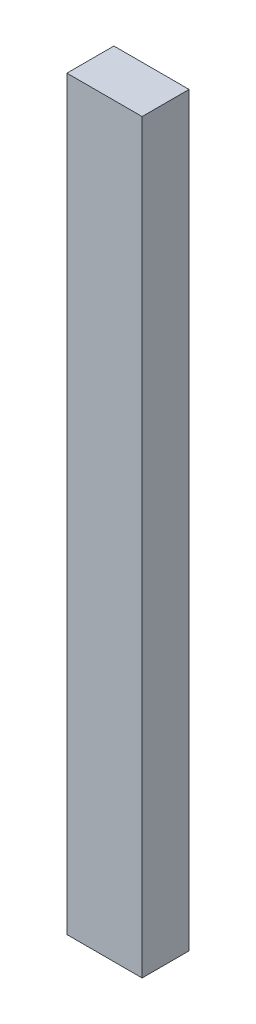
from build123d import *

# Parameters (mm, degrees)
CROQUIS1_W              = 25.4
CROQUIS1_H              = 252
SALIENTE_EXTRUIR1_DEPTH = 15.875


with BuildPart() as part:
    # Croquis1 → Saliente-Extruir1 (new body)
    with BuildSketch(Plane.XY):
        with Locations((-12.7, 126)):
            Rectangle(CROQUIS1_W, CROQUIS1_H)
    extrude(amount=SALIENTE_EXTRUIR1_DEPTH)


solid = part.part
